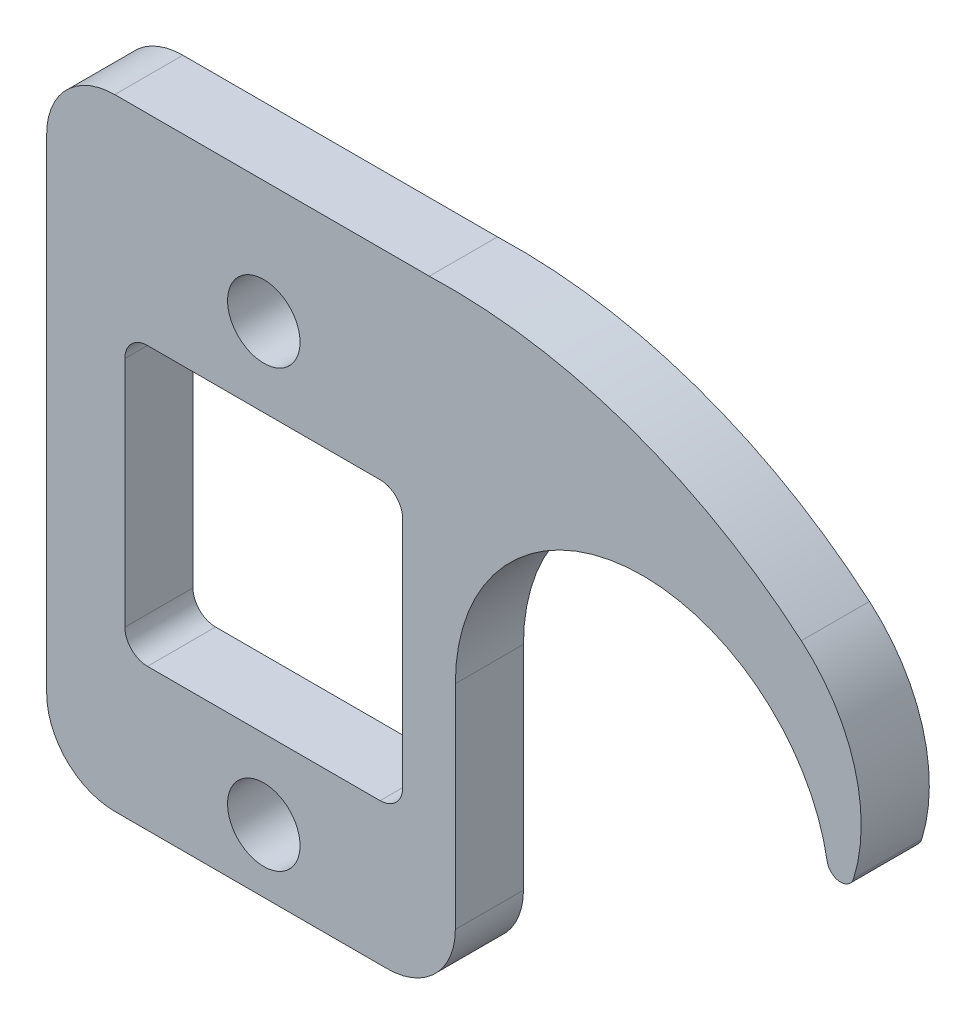
from build123d import *

# Parameters (mm, degrees)
SKETCH1_R           = 3.3782
BOSS_EXTRUDE1_DEPTH = 3.175


with BuildPart() as part:
    # Sketch1 → Boss-Extrude1 (new body, symmetric)
    with BuildSketch(Plane.XY):
        with BuildLine():
            Line((-19.885725358, 31.685738515), (-49.2125, 31.685738515))
            ThreePointArc((-49.2125, 31.685738515), (-53.702628061, 29.825866575), (-55.5625, 25.335738515))
            Line((-55.5625, 25.335738515), (-55.5625, -19.84375))
            ThreePointArc((-55.5625, -19.84375), (-53.702628061, -24.333878061), (-49.2125, -26.19375))
            Line((-49.2125, -26.19375), (-23.8125, -26.19375))
            ThreePointArc((-23.8125, -26.19375), (-19.322371939, -24.333878061), (-17.4625, -19.84375))
            Line((-17.4625, -19.84375), (-17.4625, 0))
            ThreePointArc((-17.4625, 0), (-1.497194511, 17.398198609), (17.205767985, 2.983362915))
            ThreePointArc((17.205767985, 2.983362915), (18.376051148, 1.93292337), (19.670597549, 2.825747839))
            ThreePointArc((19.670597549, 2.825747839), (19.745172941, 11.941624881), (14.793099056, 19.595495794))
            ThreePointArc((14.793099056, 19.595495794), (-1.415498584, 28.884168232), (-19.885725358, 31.685738515))
        make_face()
        with Locations((-35.321875, -20.32)):
            Circle(SKETCH1_R, mode=Mode.SUBTRACT)
        with Locations((-35.321875, 20.32)):
            Circle(SKETCH1_R, mode=Mode.SUBTRACT)
        with BuildLine():
            Line((-48.275875, 10.8458), (-48.275875, -10.8458))
            ThreePointArc((-48.275875, -10.8458), (-47.658397516, -12.336522516), (-46.167675, -12.954))
            Line((-46.167675, -12.954), (-24.476075, -12.954))
            ThreePointArc((-24.476075, -12.954), (-22.985352484, -12.336522516), (-22.367875, -10.8458))
            Line((-22.367875, -10.8458), (-22.367875, 10.8458))
            ThreePointArc((-22.367875, 10.8458), (-22.985352484, 12.336522516), (-24.476075, 12.954))
            Line((-24.476075, 12.954), (-46.167675, 12.954))
            ThreePointArc((-46.167675, 12.954), (-47.658397516, 12.336522516), (-48.275875, 10.8458))
        make_face(mode=Mode.SUBTRACT)
    extrude(amount=BOSS_EXTRUDE1_DEPTH, both=True)


solid = part.part
